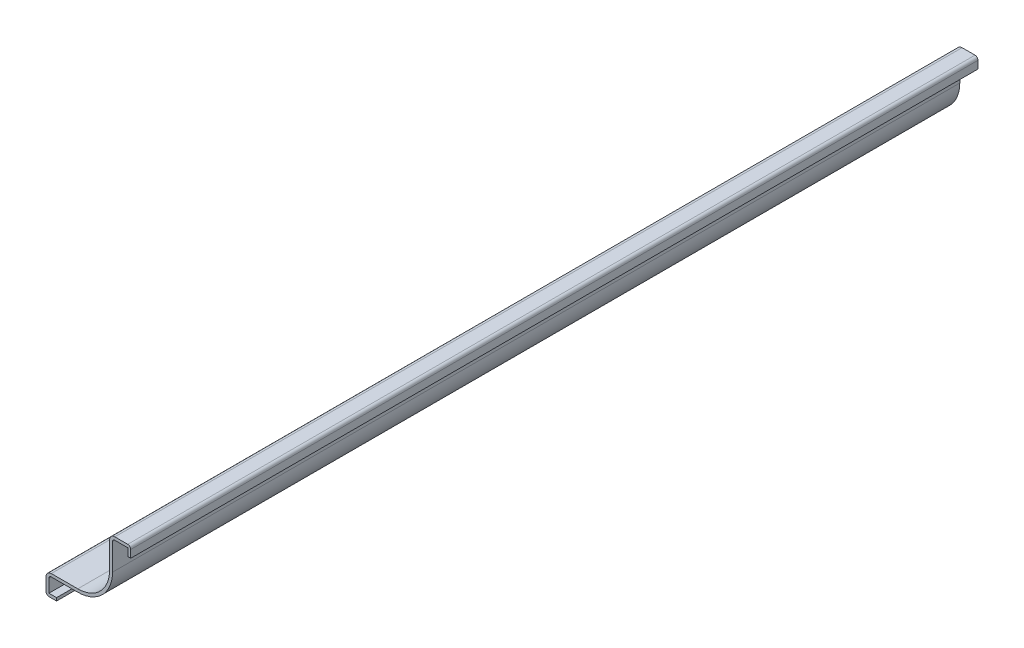
from build123d import *

# Parameters (mm, degrees)
EXTRUDE_THIN1_DEPTH = 254
FILLET1_R           = 0.889


with BuildPart() as part:
    # Sketch1 → Extrude-Thin1 (new body)
    with BuildSketch(Plane.XY):
        with BuildLine():
            Line((-22.225, 0), (-25.4, 0))
            Line((-25.4, 0), (-25.4, 4.7625))
            ThreePointArc((-25.4, 4.7625), (-24.935032015, 5.885032015), (-23.8125, 6.35))
            Line((-23.8125, 6.35), (-15.875, 6.35))
            ThreePointArc((-15.875, 6.35), (-9.139807909, 9.139807909), (-6.35, 15.875))
            Line((-6.35, 15.875), (-6.35, 23.8125))
            ThreePointArc((-6.35, 23.8125), (-5.885032015, 24.935032015), (-4.7625, 25.4))
            Line((-4.7625, 25.4), (0, 25.4))
            Line((0, 25.4), (0, 22.225))
            Line((0, 22.225), (-0.889, 22.225))
            Line((-0.889, 22.225), (-0.889, 24.511))
            Line((-0.889, 24.511), (-4.7625, 24.511))
            ThreePointArc((-4.7625, 24.511), (-5.256414087, 24.306414087), (-5.461, 23.8125))
            Line((-5.461, 23.8125), (-5.461, 15.875))
            ThreePointArc((-5.461, 15.875), (-8.511189981, 8.511189981), (-15.875, 5.461))
            Line((-15.875, 5.461), (-23.8125, 5.461))
            ThreePointArc((-23.8125, 5.461), (-24.306414087, 5.256414087), (-24.511, 4.7625))
            Line((-24.511, 4.7625), (-24.511, 0.889))
            Line((-24.511, 0.889), (-22.225, 0.889))
            Line((-22.225, 0.889), (-22.225, 0))
        make_face()
    extrude(amount=-EXTRUDE_THIN1_DEPTH)

    # Fillet1
    fillet1_edges = [part.edges().sort_by_distance(p)[0] for p in [
        (-25.4, 0, -127),
        (0, 25.4, -127),
    ]]
    fillet(fillet1_edges, radius=FILLET1_R)


solid = part.part
